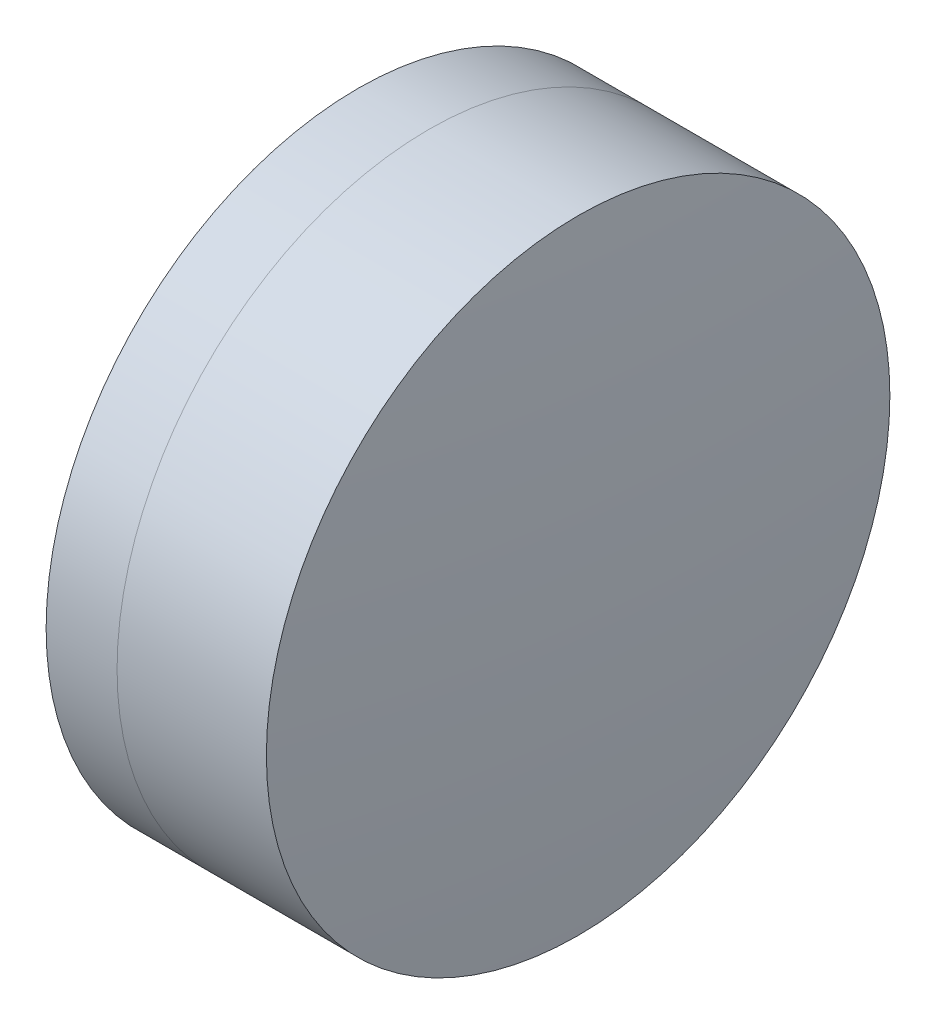
from build123d import *


with BuildPart() as part:
    # 草图1 one side → 旋转1 (revolve)
    with BuildSketch(Plane(origin=(0, 0, 0), x_dir=(1, 0, 0), z_dir=(0, 1, 0)), mode=Mode.PRIVATE) as revolve_1_sk:
        with BuildLine():
            ThreePointArc((266.409277533, 4), (265.95548559, 2.022837248), (265.803074491, 0))
            Line((265.803074491, 0), (268.103074491, 0))
            ThreePointArc((268.103074491, 0), (267.90530784, 2.038023883), (267.319387444, 4))
            Line((267.319387444, 4), (266.409277533, 4))
        make_face()
    revolve(revolve_1_sk.sketch.rotate(Axis((124.523309526, 0, 0), (1, 0, 0)), 180), axis=Axis((124.523309526, 0, 0), (1, 0, 0)))  # turned: the seam where the file's is


with BuildPart() as body_2:
    # 草图2 one side → 旋转3 (revolve)
    with BuildSketch(Plane(origin=(0, 0, 0), x_dir=(1, 0, 0), z_dir=(0, 1, 0)), mode=Mode.PRIVATE) as revolve_3_sk:
        with BuildLine():
            Line((269.235416445, 4), (267.319387444, 4))
            ThreePointArc((267.319387444, 4), (267.90530784, 2.038023883), (268.103074491, 0))
            Line((268.103074491, 0), (269.403074491, 0))
            ThreePointArc((269.403074491, 0), (269.361141586, 2.001756055), (269.235416445, 4))
        make_face()
    revolve(revolve_3_sk.sketch.rotate(Axis((-0.551919993, 0, 0), (1, 0, 0)), 180), axis=Axis((-0.551919993, 0, 0), (1, 0, 0)))  # turned: the seam where the file's is


solid = Compound([part.part, body_2.part])
